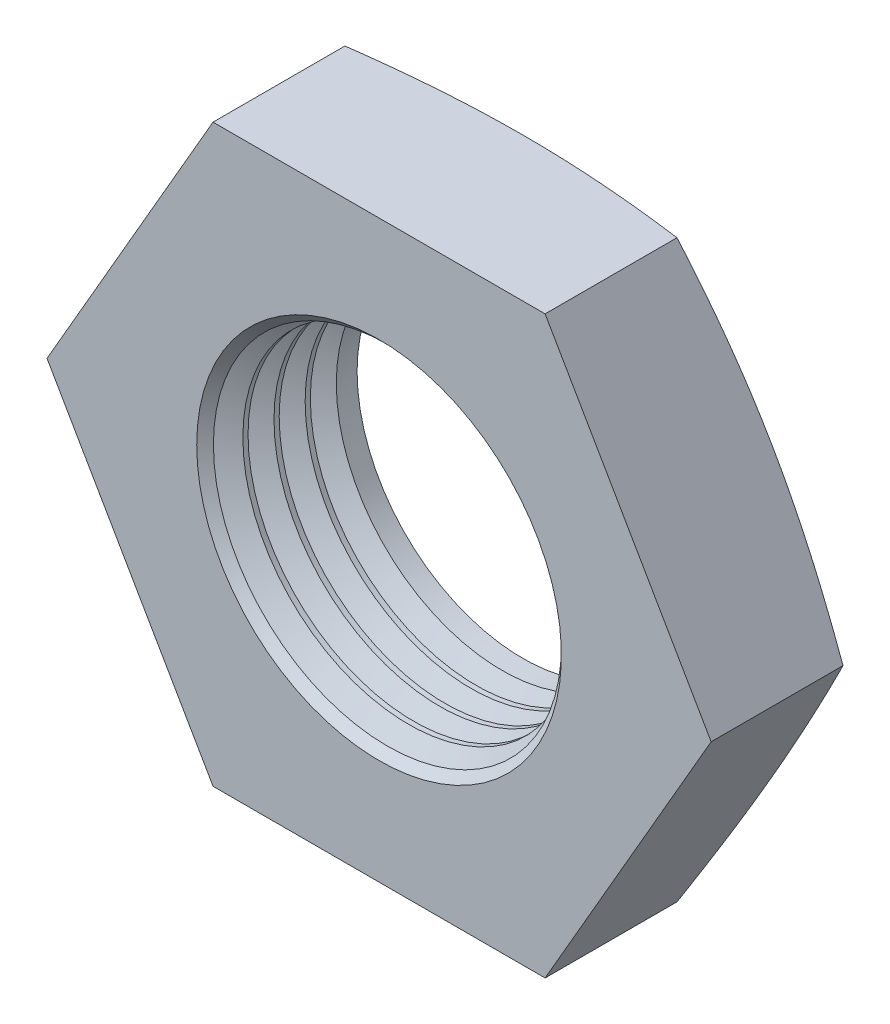
from build123d import *

# Parameters (mm, degrees)
SKETCH1_R        = 3.4585
BASENUT_DEPTH    = 3
CHAMFER1_SIZE    = 0.34585
LPATTERN10_COUNT = 4
LPATTERN10_PITCH = 0.6498


with BuildPart() as part:
    # Sketch1 → BaseNut (new body)
    with BuildSketch(Plane.XY):
        Polygon((3.464101615, -6), (6.92820323, 0), (3.464101615, 6), (-3.464101615, 6), (-6.92820323, 0), (-3.464101615, -6), align=None)
        Circle(SKETCH1_R, mode=Mode.SUBTRACT)
    extrude(amount=-BASENUT_DEPTH)

    # Sketch2 → Double-Chamfer (revolve, cut)
    with BuildSketch(Plane(origin=(0, 0, 0), x_dir=(1, 0, 0), z_dir=(0, 1, 0))):
        Polygon((-6.92820323, 3), (-6, 3), (-6.92820323, 2.751288694), align=None)
    revolve(axis=Axis((0, 0, -3.375940562), (0, 0, 1)), mode=Mode.SUBTRACT)

    # Chamfer1
    chamfer1_edges = [part.edges().sort_by_distance(p)[0] for p in [
        (-3.4585, 0, 0),
    ]]
    chamfer(chamfer1_edges, length=CHAMFER1_SIZE)

    # Sketch3 → Cut-Revolve10 (revolve, cut)
    with BuildSketch(Plane(origin=(0, 0, 0), x_dir=(1, 0, 0), z_dir=(0, 1, 0))):
        Polygon((2.917, 0.6166), (3.4585, 0.6166), (3.927452756, 0.34585), (3.4585, 0.0751), (2.917, 0.0751), align=None)
    cut_revolve10 = revolve(axis=Axis((0, 0, -2.739364781), (0, 0, 1)), mode=Mode.SUBTRACT)

    # LPattern10: Cut-Revolve10 ×4
    with Locations(*[(0, 0, -i * LPATTERN10_PITCH) for i in range(1, LPATTERN10_COUNT)]):
        add(cut_revolve10, mode=Mode.SUBTRACT)


solid = part.part
